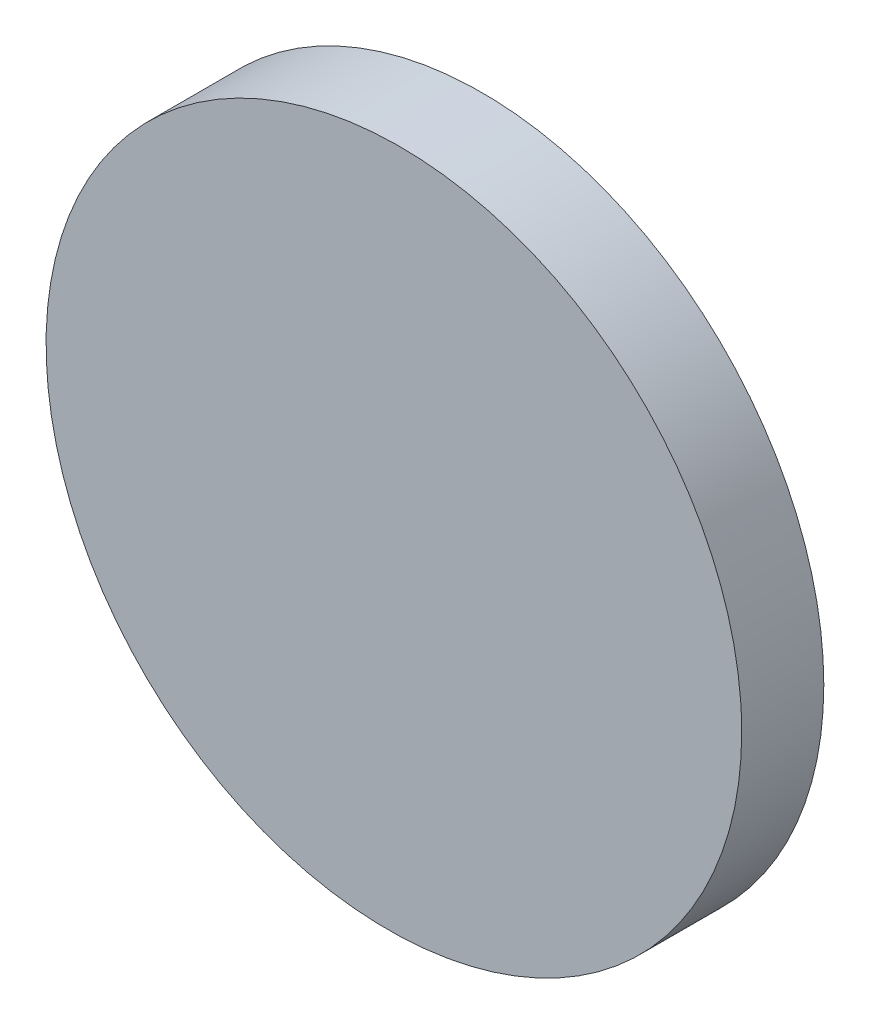
from build123d import *

# Parameters (mm, degrees)
SKETCH_1_R          = 12.5
EXTRUDE_1_DEPTH     = 10
CUT_EXTRUDE_1_DEPTH = 25


with BuildPart() as part:
    # 草图1 → 凸台-拉伸1 (new body)
    with BuildSketch(Plane.XY):
        Circle(SKETCH_1_R)
    extrude(amount=EXTRUDE_1_DEPTH)

    # 草图2 → 切除-拉伸1 (cut, symmetric)
    with BuildSketch(Plane(origin=(0, 0, 0), x_dir=(1, 0, 0), z_dir=(0, 1, 0))):
        Polygon((12.5, -3), (-16.637968604, -3.493344019), (-16.637968604, -14.431177009), (17.770862478, -14.431177009), (17.770862478, -3), align=None)
    extrude(amount=CUT_EXTRUDE_1_DEPTH, both=True, mode=Mode.SUBTRACT)


solid = part.part
